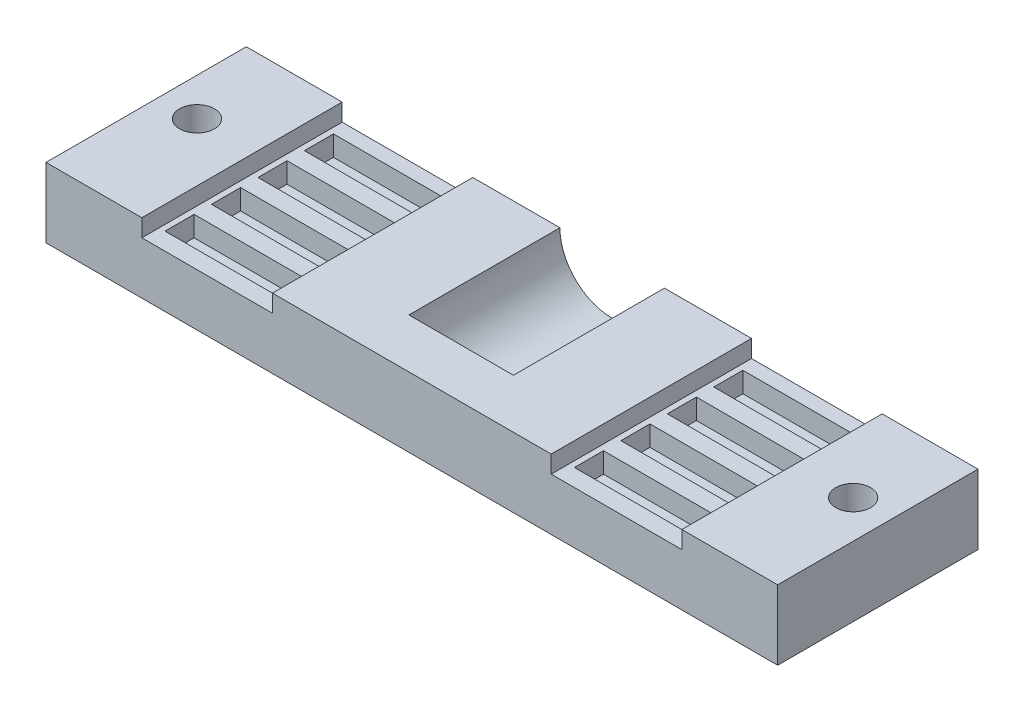
from build123d import *

# Parameters (mm, degrees)
SALIENTE_EXTRUIR1_DEPTH = 34.5
CROQUIS2_R              = 9
CORTAR_EXTRUIR1_DEPTH   = 26
CROQUIS3_W              = 10
CROQUIS3_H              = 5
CROQUIS3_W_2            = 10.5
CROQUIS3_W_3            = 20.5
CORTAR_EXTRUIR2_DEPTH   = 3.5
CROQUIS4_R              = 3
CORTAR_EXTRUIR3_DEPTH   = 13


with BuildPart() as part:
    # Croquis1 → Saliente-Extruir1 (new body)
    with BuildSketch(Plane.XY):
        Polygon((0, 0), (0, 12), (16.5, 12), (16.5, 9), (39, 9), (39, 12), (87, 12), (87, 9), (109.5, 9), (109.5, 12), (126, 12), (126, 0), align=None)
    extrude(amount=SALIENTE_EXTRUIR1_DEPTH)

    # Croquis2 → Cortar-Extruir1 (cut)
    with BuildSketch(Plane(origin=(0, 0, 0), x_dir=(-1, 0, 0), z_dir=(0, 0, -1))):
        with Locations((-63, 12)):
            Circle(CROQUIS2_R)
    extrude(amount=-CORTAR_EXTRUIR1_DEPTH, mode=Mode.SUBTRACT)

    # Croquis3 → Cortar-Extruir2 (cut)
    with BuildSketch(Plane(origin=(0, 9, 0), x_dir=(1, 0, 0), z_dir=(0, 1, 0))):
        with Locations((22.5, -29)):
            Rectangle(CROQUIS3_W, CROQUIS3_H)
        with Locations((32.75, -29)):
            Rectangle(CROQUIS3_W_2, CROQUIS3_H)
        with Locations((32.75, -21)):
            Rectangle(CROQUIS3_W_2, CROQUIS3_H)
        with Locations((22.5, -21)):
            Rectangle(CROQUIS3_W, CROQUIS3_H)
        with Locations((32.75, -13)):
            Rectangle(CROQUIS3_W_2, CROQUIS3_H)
        with Locations((22.5, -13)):
            Rectangle(CROQUIS3_W, CROQUIS3_H)
        with Locations((32.75, -5)):
            Rectangle(CROQUIS3_W_2, CROQUIS3_H)
        with Locations((22.5, -5)):
            Rectangle(CROQUIS3_W, CROQUIS3_H)
        with Locations((98.25, -29)):
            Rectangle(CROQUIS3_W_3, CROQUIS3_H)
        with Locations((98.25, -21)):
            Rectangle(CROQUIS3_W_3, CROQUIS3_H)
        with Locations((98.25, -13)):
            Rectangle(CROQUIS3_W_3, CROQUIS3_H)
        with Locations((98.25, -5)):
            Rectangle(CROQUIS3_W_3, CROQUIS3_H)
    extrude(amount=-CORTAR_EXTRUIR2_DEPTH, mode=Mode.SUBTRACT)

    # Croquis4 → Cortar-Extruir3 (cut, through all)
    with BuildSketch(Plane(origin=(0, 12, 0), x_dir=(1, 0, 0), z_dir=(0, 1, 0))):
        with Locations((6.5, -15)):
            Circle(CROQUIS4_R)
    cortar_extruir3 = extrude(amount=-CORTAR_EXTRUIR3_DEPTH, mode=Mode.SUBTRACT)

    # Simetría1: Cortar-Extruir3 across plane
    add(cortar_extruir3.mirror(Plane.ZY.offset(-63)), mode=Mode.SUBTRACT)


solid = part.part
